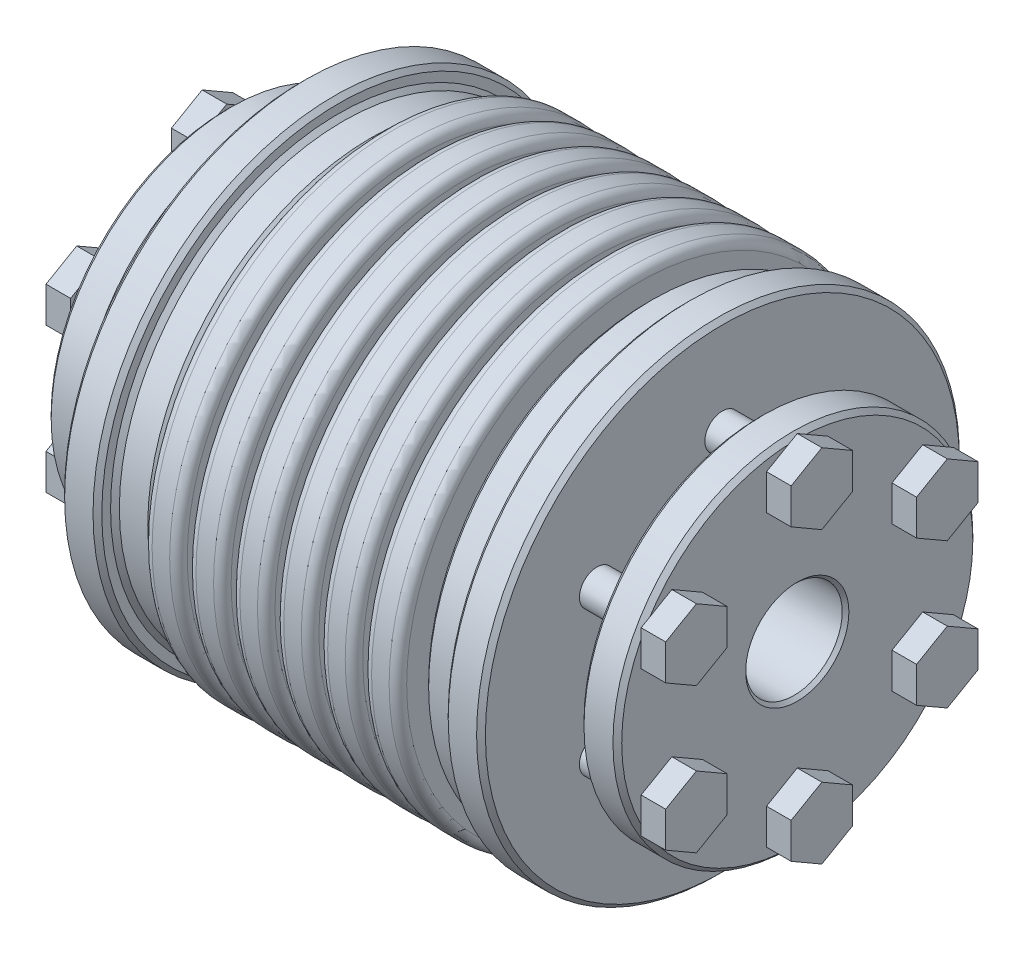
from build123d import *

# Parameters (mm, degrees)
SKETCH1_R                      = 27.5
BOSS_EXTRUDE1_DEPTH            = 32.5
SKETCH2_R                      = 5.5
CUT_EXTRUDE1_DEPTH             = 19
CHAMFER1_SIZE                  = 0.381
CUT_EXTRUDE2_REACH             = 34.5
SKETCH5_R                      = 16.6905
CUT_EXTRUDE2_DIRECTION_2_REACH = 34.5
SKETCH8_W                      = 1
SKETCH8_H                      = 8.8095
FILLET1_R                      = 1
FILLET2_R                      = 0.25
BOSS_EXTRUDE2_DEPTH            = 2.8
BOSS_EXTRUDE2_2_DEPTH          = 2.8
BOSS_EXTRUDE2_3_DEPTH          = 2.8
BOSS_EXTRUDE2_4_DEPTH          = 2.8
BOSS_EXTRUDE2_5_DEPTH          = 2.8
BOSS_EXTRUDE2_6_DEPTH          = 2.8
SKETCH11_R                     = 2
BOSS_EXTRUDE3_DEPTH            = 11.332656
CHAMFER2_SIZE                  = 0.5


with BuildPart() as part:
    # Sketch1 → Boss-Extrude1 (new body, symmetric)
    with BuildSketch(Plane(origin=(0, 0, 0), x_dir=(0, 0, -1), z_dir=(1, 0, 0))):
        Circle(SKETCH1_R)
    extrude(amount=BOSS_EXTRUDE1_DEPTH, both=True)

    # Sketch2 → Cut-Extrude1 (cut)
    with BuildSketch(Plane(origin=(32.5, 0, 0), x_dir=(0, 0, -1), z_dir=(1, 0, 0))):
        Circle(SKETCH2_R)
    cut_extrude1 = extrude(amount=-CUT_EXTRUDE1_DEPTH, mode=Mode.SUBTRACT)

    # Mirror3: Cut-Extrude1 across plane
    add(cut_extrude1.mirror(Plane(origin=(0, 0, 0), x_dir=(0, 0, 1), z_dir=(1, 0, 0))), mode=Mode.SUBTRACT)

    # Chamfer1
    chamfer1_edges = [part.edges().sort_by_distance(p)[0] for p in [
        (-32.5, 0, 27.5),
        (32.5, 0, 27.5),
        (32.5, 0, 5.5),
        (-32.5, 0, 5.5),
    ]]
    chamfer(chamfer1_edges, length=CHAMFER1_SIZE)

    # Cut-Extrude2: up to this face of the body (flat: up to its plane)
    cut_extrude2_end = Plane(part.part.faces().sort_by_distance((-13.5, 0, 0))[0])
    # Sketch5 → Cut-Extrude2 (cut, up to the picked face)
    with BuildSketch(Plane(origin=(0, 0, 0), x_dir=(0, 0, -1), z_dir=(1, 0, 0)), mode=Mode.PRIVATE) as cut_extrude2_sk1:
        Circle(SKETCH5_R)
    cut_extrude2_tool1 = split(extrude(cut_extrude2_sk1.sketch, amount=-CUT_EXTRUDE2_REACH, mode=Mode.PRIVATE), bisect_by=cut_extrude2_end, keep=Keep.BOTH, mode=Mode.PRIVATE)
    add(cut_extrude2_tool1.solids().sort_by(Axis((0, 0, 0), (-1, 0, 0)))[0], mode=Mode.SUBTRACT)

    # Cut-Extrude2 direction 2: up to this face of the body (flat: up to its plane)
    cut_extrude2_direction_2_end = Plane(part.part.faces().sort_by_distance((13.5, 0, 0))[0])
    # Sketch5 → Cut-Extrude2 direction 2 (cut, up to the picked face)
    with BuildSketch(Plane(origin=(0, 0, 0), x_dir=(0, 0, -1), z_dir=(1, 0, 0)), mode=Mode.PRIVATE) as cut_extrude2_direction_2_sk1:
        Circle(SKETCH5_R)
    cut_extrude2_direction_2_tool1 = split(extrude(cut_extrude2_direction_2_sk1.sketch, amount=CUT_EXTRUDE2_DIRECTION_2_REACH, mode=Mode.PRIVATE), bisect_by=cut_extrude2_direction_2_end, keep=Keep.BOTH, mode=Mode.PRIVATE)
    add(cut_extrude2_direction_2_tool1.solids().sort_by(Axis((0, 0, 0), (1, 0, 0)))[0], mode=Mode.SUBTRACT)

    # Sketch8 → Cut-Revolve1 (revolve, cut)
    with BuildSketch(Plane(origin=(0, 0, 0), x_dir=(1, 0, 0), z_dir=(0, 1, 0)), mode=Mode.PRIVATE) as cut_revolve1_sk:
        with Locations((0, 23.09525)):
            Rectangle(SKETCH8_W, SKETCH8_H)
        with Locations((5, 23.09525)):
            Rectangle(SKETCH8_W, SKETCH8_H)
        with Locations((10, 23.09525)):
            Rectangle(SKETCH8_W, SKETCH8_H)
        with Locations((15, 23.09525)):
            Rectangle(SKETCH8_W, SKETCH8_H)
    cut_revolve1 = revolve(cut_revolve1_sk.sketch.rotate(Axis((0, 0, 0), (1, 0, 0)), 180), axis=Axis((0, 0, 0), (1, 0, 0)), mode=Mode.SUBTRACT)  # turned: the seam where the file's is

    # Mirror2: Cut-Revolve1 across plane
    add(cut_revolve1.mirror(Plane(origin=(0, 0, 0), x_dir=(0, 0, 1), z_dir=(1, 0, 0))), mode=Mode.SUBTRACT)

    # Fillet1
    fillet1_edges = [part.edges().sort_by_distance(p)[0] for p in [
        (-0.5, 0, 27.5),
        (0.5, 0, 27.5),
        (14.5, 0, 27.5),
        (15.5, 0, 27.5),
        (4.5, 0, 27.5),
        (5.5, 0, 27.5),
        (9.5, 0, 27.5),
        (10.5, 0, 27.5),
        (-15.5, 0, 27.5),
        (-14.5, 0, 27.5),
        (-4.5, 0, 27.5),
        (-5.5, 0, 27.5),
        (-9.5, 0, 27.5),
        (-10.5, 0, 27.5),
    ]]
    fillet(fillet1_edges, radius=FILLET1_R)

    # Fillet2
    fillet2_edges = [part.edges().sort_by_distance(p)[0] for p in [
        (0.5, 0, -18.6905),
        (-0.5, 0, -18.6905),
        (15.5, 0, -18.6905),
        (14.5, 0, -18.6905),
        (5.5, 0, -18.6905),
        (4.5, 0, -18.6905),
        (10.5, 0, -18.6905),
        (9.5, 0, -18.6905),
        (-15.5, 0, -18.6905),
        (-14.5, 0, -18.6905),
        (-4.5, 0, -18.6905),
        (-5.5, 0, -18.6905),
        (-9.5, 0, -18.6905),
        (-10.5, 0, -18.6905),
    ]]
    fillet(fillet2_edges, radius=FILLET2_R)

    # Sketch9 → Cut-Revolve2 (revolve, cut)
    with BuildSketch(Plane.XY, mode=Mode.PRIVATE) as cut_revolve2_sk:
        Polygon((15.5, 25.5), (19.733672196, 25.5), (19.733672196, 27.5), (23.967344391, 27.5), (23.967344391, 11.753489364), (28.201016587, 12.5), (28.201016587, 20.5), (32.5, 20.5), (32.5, 32.5), (15.5, 32.5), align=None)
        Polygon((-15.5, 32.5), (-15.5, 25.5), (-19.733672196, 25.5), (-19.733672196, 27.5), (-23.967344391, 27.5), (-23.967344391, 11.753489364), (-28.201016587, 12.5), (-28.201016587, 20.5), (-32.5, 20.5), (-32.5, 32.5), align=None)
    revolve(cut_revolve2_sk.sketch.rotate(Axis((32.5, 0, 0), (-1, 0, 0)), 270), axis=Axis((32.5, 0, 0), (-1, 0, 0)), mode=Mode.SUBTRACT)  # turned: the seam where the file's is

    # Chamfer2
    chamfer2_edges = [part.edges().sort_by_distance(p)[0] for p in [
        (15.5, 0, -25.5),
        (19.733672196, 0, -25.5),
        (19.733672196, 0, 27.5),
        (23.967344391, 0, 27.5),
        (28.201016587, 0, -20.5),
        (32.5, 0, -20.5),
        (-28.201016587, 0, -20.5),
        (-32.5, 0, -20.5),
        (-15.5, 0, -25.5),
        (-19.733672196, 0, -25.5),
        (-19.733672196, 0, 27.5),
        (-23.967344391, 0, 27.5),
    ]]
    chamfer(chamfer2_edges, length=CHAMFER2_SIZE)


with BuildPart() as body_2:
    # Sketch10 → Boss-Extrude2 (new body)
    with BuildSketch(Plane(origin=(32.5, 0, 0), x_dir=(0, 0, -1), z_dir=(1, 0, 0))):
        Polygon((10.789419162, 6.229274058), (14.289419162, 4.208548116), (17.789419162, 6.229274058), (17.789419162, 10.270725942), (14.289419162, 12.291451884), (10.789419162, 10.270725942), align=None)
    extrude(amount=BOSS_EXTRUDE2_DEPTH)


with BuildPart() as body_3:
    # Sketch10 → Boss-Extrude2 2 (new body)
    with BuildSketch(Plane(origin=(32.5, 0, 0), x_dir=(0, 0, -1), z_dir=(1, 0, 0))):
        Polygon((0, 12.458548116), (3.5, 14.479274058), (3.5, 18.520725942), (0, 20.541451884), (-3.5, 18.520725942), (-3.5, 14.479274058), align=None)
    extrude(amount=BOSS_EXTRUDE2_2_DEPTH)


    add(body_2.part)  # Boss-Extrude3 merges body 2


with BuildPart() as body_4:
    # Sketch10 → Boss-Extrude2 3 (new body)
    with BuildSketch(Plane(origin=(32.5, 0, 0), x_dir=(0, 0, -1), z_dir=(1, 0, 0))):
        Polygon((10.789419162, -6.229274058), (10.789419162, -10.270725942), (14.289419162, -12.291451884), (17.789419162, -10.270725942), (17.789419162, -6.229274058), (14.289419162, -4.208548116), align=None)
    extrude(amount=BOSS_EXTRUDE2_3_DEPTH)


with BuildPart() as body_5:
    # Sketch10 → Boss-Extrude2 4 (new body)
    with BuildSketch(Plane(origin=(32.5, 0, 0), x_dir=(0, 0, -1), z_dir=(1, 0, 0))):
        Polygon((0, -12.458548116), (-3.5, -14.479274058), (-3.5, -18.520725942), (0, -20.541451884), (3.5, -18.520725942), (3.5, -14.479274058), align=None)
    extrude(amount=BOSS_EXTRUDE2_4_DEPTH)


with BuildPart() as body_6:
    # Sketch10 → Boss-Extrude2 5 (new body)
    with BuildSketch(Plane(origin=(32.5, 0, 0), x_dir=(0, 0, -1), z_dir=(1, 0, 0))):
        Polygon((-10.789419162, -6.229274058), (-14.289419162, -4.208548116), (-17.789419162, -6.229274058), (-17.789419162, -10.270725942), (-14.289419162, -12.291451884), (-10.789419162, -10.270725942), align=None)
    extrude(amount=BOSS_EXTRUDE2_5_DEPTH)


with BuildPart() as body_7:
    # Sketch10 → Boss-Extrude2 6 (new body)
    with BuildSketch(Plane(origin=(32.5, 0, 0), x_dir=(0, 0, -1), z_dir=(1, 0, 0))):
        Polygon((-10.789419162, 6.229274058), (-10.789419162, 10.270725942), (-14.289419162, 12.291451884), (-17.789419162, 10.270725942), (-17.789419162, 6.229274058), (-14.289419162, 4.208548116), align=None)
    extrude(amount=BOSS_EXTRUDE2_6_DEPTH)


with BuildPart() as body_3_1:
    add(body_3.part)

    add(body_4.part)  # Boss-Extrude3 merges body 4

    add(body_5.part)  # Boss-Extrude3 merges body 5

    add(body_6.part)  # Boss-Extrude3 merges body 6

    add(body_7.part)  # Boss-Extrude3 merges body 7
    # Sketch11 → Boss-Extrude3 (add)
    with BuildSketch(Plane(origin=(35.3, 0, 0), x_dir=(0, 0, -1), z_dir=(1, 0, 0))):
        with Locations((0, 16.5)):
            Circle(SKETCH11_R)
        with Locations((14.289419162, 8.25)):
            Circle(SKETCH11_R)
        with Locations((14.289419162, -8.25)):
            Circle(SKETCH11_R)
        with Locations((0, -16.5)):
            Circle(SKETCH11_R)
        with Locations((-14.289419162, -8.25)):
            Circle(SKETCH11_R)
        with Locations((-14.289419162, 8.25)):
            Circle(SKETCH11_R)
    extrude(amount=-BOSS_EXTRUDE3_DEPTH)


with BuildPart() as body_3_2:
    # Mirror5: mirrored copy
    add(body_3_1.part.mirror(Plane(origin=(0, 0, 0), x_dir=(0, 0, 1), z_dir=(1, 0, 0))))


solid = Compound([part.part, body_3_1.part, body_3_2.part])
